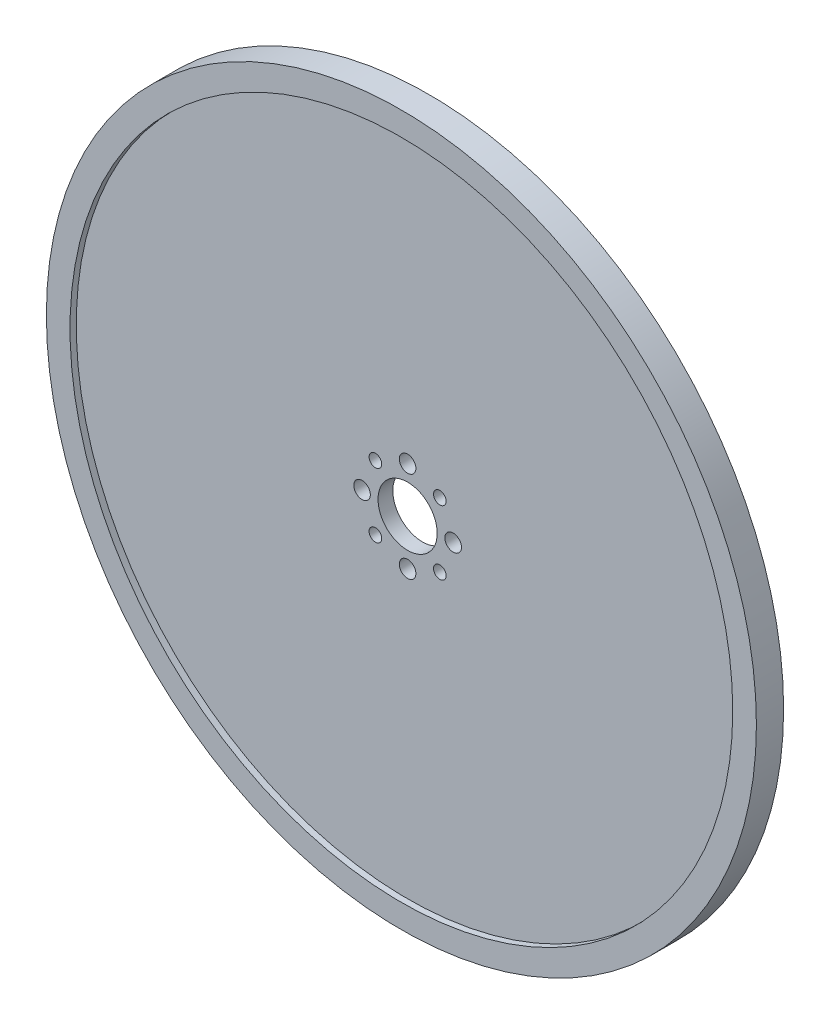
from build123d import *

# Parameters (mm, degrees)
SKETCH1_R                 = 76.2
SKETCH1_R_2               = 71.12
BOSS_EXTRUDE1_DEPTH       = 2.921
SKETCH3_R                 = 71.12
SKETCH3_R_2               = 6.35
SKETCH3_R_3               = 1.778
BOSS_EXTRUDE2_DEPTH       = 1.5875
F_6_32_TAPPED_HOLE1_D     = 2.7051
F_6_32_TAPPED_HOLE1_DEPTH = 3.175


with BuildPart() as part:
    # Sketch1 → Boss-Extrude1 (new body, symmetric)
    with BuildSketch(Plane.XY):
        Circle(SKETCH1_R)
        Circle(SKETCH1_R_2, mode=Mode.SUBTRACT)
    extrude(amount=BOSS_EXTRUDE1_DEPTH, both=True)

    # Sketch3 → Boss-Extrude2 (add, symmetric)
    with BuildSketch(Plane.XY):
        Circle(SKETCH3_R)
        Circle(SKETCH3_R_2, mode=Mode.SUBTRACT)
        with Locations((0, 9.779)):
            Circle(SKETCH3_R_3, mode=Mode.SUBTRACT)
        with Locations((9.779, 0)):
            Circle(SKETCH3_R_3, mode=Mode.SUBTRACT)
        with Locations((0, -9.779)):
            Circle(SKETCH3_R_3, mode=Mode.SUBTRACT)
        with Locations((-9.779, 0)):
            Circle(SKETCH3_R_3, mode=Mode.SUBTRACT)
    extrude(amount=BOSS_EXTRUDE2_DEPTH, both=True)

    # #6-32 Tapped Hole1
    with Locations(Plane.XY.offset(1.5875)):
        with Locations((-6.914797213, 6.914797213), (6.914797213, 6.914797213), (6.914797213, -6.914797213), (-6.914797213, -6.914797213)):
            Hole(F_6_32_TAPPED_HOLE1_D / 2, depth=F_6_32_TAPPED_HOLE1_DEPTH)


solid = part.part
